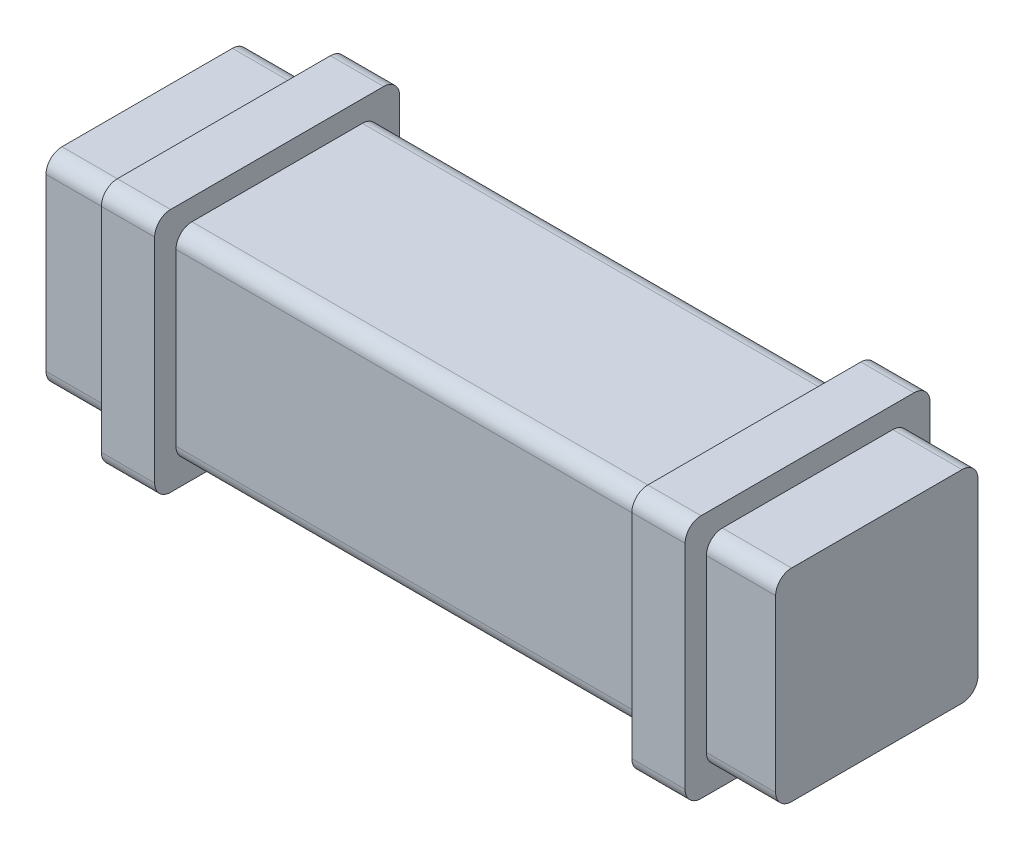
from build123d import *

# Parameters (mm, degrees)
EXTRUDE_1_DEPTH = 137
EXTRUDE_START   = -14.4
EXTRUDE_2_DEPTH = 10
EXTRUDE_START_2 = -114
EXTRUDE_3_DEPTH = 10


with BuildPart() as part:
    # 스케치1 → 보스-돌출1 (new body)
    with BuildSketch(Plane.YZ):
        with BuildLine():
            Line((-16, 19), (16, 19))
            ThreePointArc((16, 19), (18.121320344, 18.121320344), (19, 16))
            Line((19, 16), (19, -16))
            ThreePointArc((19, -16), (18.121320344, -18.121320344), (16, -19))
            Line((16, -19), (-16, -19))
            ThreePointArc((-16, -19), (-18.121320344, -18.121320344), (-19, -16))
            Line((-19, -16), (-19, 16))
            ThreePointArc((-19, 16), (-18.121320344, 18.121320344), (-16, 19))
        make_face()
    extrude(amount=EXTRUDE_1_DEPTH)

    # 스케치2 → 보스-돌출2 (add)
    with BuildSketch(Plane(origin=(0, 0, 0), x_dir=(0, -1, 0), z_dir=(-1, 0, 0)).offset(EXTRUDE_START)):
        with BuildLine():
            Line((-20, 23), (20, 23))
            ThreePointArc((20, 23), (22.121320344, 22.121320344), (23, 20))
            Line((23, 20), (23, -20))
            ThreePointArc((23, -20), (22.121320344, -22.121320344), (20, -23))
            Line((20, -23), (-20, -23))
            ThreePointArc((-20, -23), (-22.121320344, -22.121320344), (-23, -20))
            Line((-23, -20), (-23, 20))
            ThreePointArc((-23, 20), (-22.121320344, 22.121320344), (-20, 23))
        make_face()
    extrude(amount=-EXTRUDE_2_DEPTH)

    # 스케치2<2> → 보스-돌출3 (add)
    with BuildSketch(Plane(origin=(0, 0, 0), x_dir=(0, -1, 0), z_dir=(-1, 0, 0)).offset(EXTRUDE_START_2)):
        with BuildLine():
            Line((-20, 23), (20, 23))
            ThreePointArc((20, 23), (22.121320344, 22.121320344), (23, 20))
            Line((23, 20), (23, -20))
            ThreePointArc((23, -20), (22.121320344, -22.121320344), (20, -23))
            Line((20, -23), (-20, -23))
            ThreePointArc((-20, -23), (-22.121320344, -22.121320344), (-23, -20))
            Line((-23, -20), (-23, 20))
            ThreePointArc((-23, 20), (-22.121320344, 22.121320344), (-20, 23))
        make_face()
    extrude(amount=-EXTRUDE_3_DEPTH)


solid = part.part
